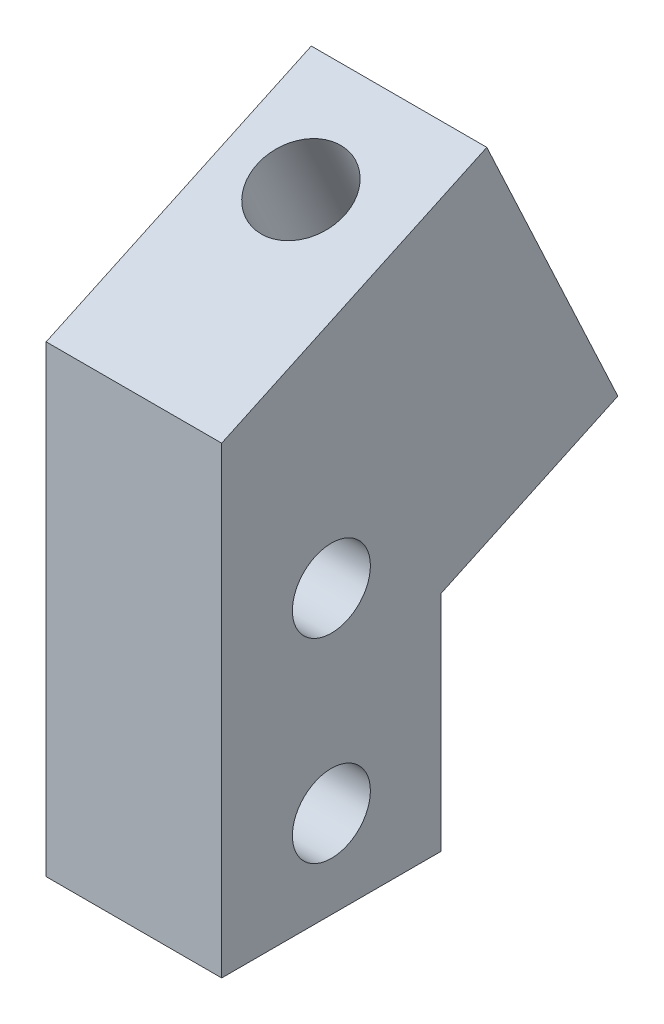
from build123d import *

# Parameters (mm, degrees)
SKETCH1_R           = 4
BOSS_EXTRUDE1_DEPTH = 18
SKETCH2_R           = 4.5
CUT_EXTRUDE1_DEPTH  = 61.218975205


with BuildPart() as part:
    # Sketch1 → Boss-Extrude1 (new body)
    with BuildSketch(Plane(origin=(0, 0, 0), x_dir=(0, 0, -1), z_dir=(1, 0, 0))):
        Polygon((-11.25, 23.75), (15.939233611, 36.428547852), (29.376155741, 7.612975355), (11.25, -0.83938988), (11.25, -23.75), (-11.25, -23.75), align=None)
        with Locations((0, -14.75)):
            Circle(SKETCH1_R, mode=Mode.SUBTRACT)
        with Locations((0, 5.25)):
            Circle(SKETCH1_R, mode=Mode.SUBTRACT)
    extrude(amount=BOSS_EXTRUDE1_DEPTH)

    # Sketch2 → Cut-Extrude1 (cut, through all)
    with BuildSketch(Plane(origin=(0, 23.817102858, 11.106097458), x_dir=(1, 0, 0), z_dir=(0, 0.906307787, 0.422618262))):
        with Locations((8, 19.841221112)):
            Circle(SKETCH2_R)
    extrude(amount=-CUT_EXTRUDE1_DEPTH, mode=Mode.SUBTRACT)


solid = part.part
